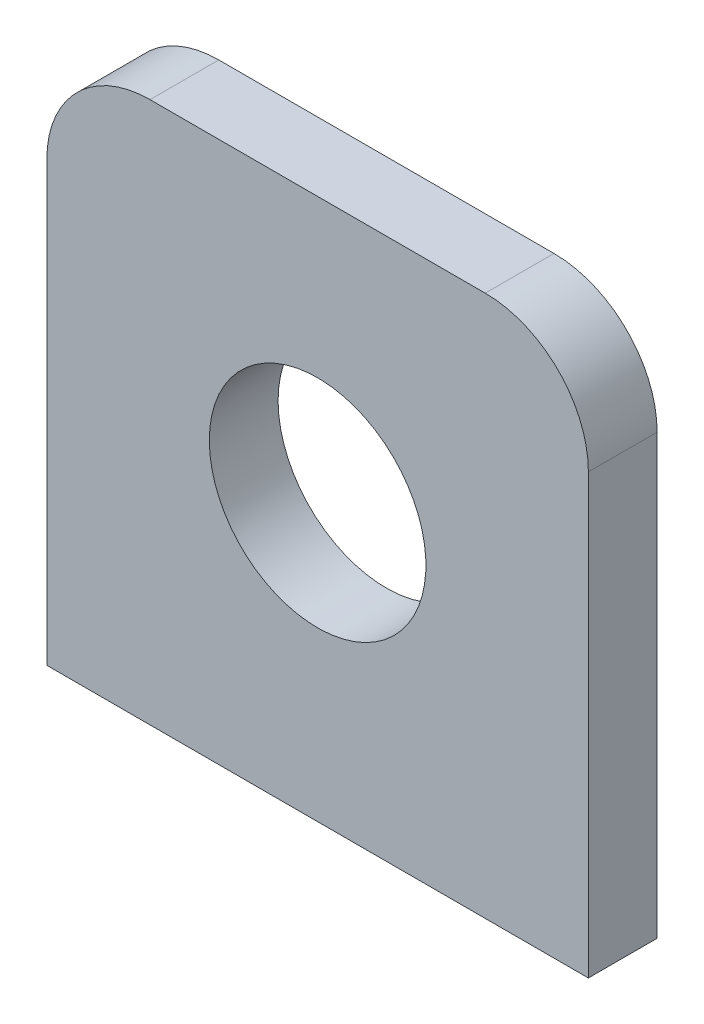
from build123d import *

# Parameters (mm, degrees)
ESBO_O1_W                        = 50
ESBO_O1_H                        = 50
RESSALTO_EXTRUS_O1_DEPTH         = 6.35
FURO_COM_FOLGA_DE_M131_D         = 20
FURO_DE_DI_METRO_3_3_3_3_2_D     = 3.3
FURO_DE_DI_METRO_3_3_3_3_2_DEPTH = 9.1
FURO_DE_DI_METRO_3_3_3_3_2_TIP   = 0.991420021
FILETE1_R                        = 9.525


with BuildPart() as part:
    # Esboço1 → Ressalto-extrusão1 (new body)
    with BuildSketch(Plane.XY.offset(6.35)):
        with Locations((12, 25)):
            Rectangle(ESBO_O1_W, ESBO_O1_H)
    extrude(amount=-RESSALTO_EXTRUS_O1_DEPTH)

    # Furo com folga de M131 (through all)
    with Locations(Plane(origin=(0, 0, 0), x_dir=(-1, 0, 0), z_dir=(0, 0, -1))):
        with Locations((-12, 25.5)):
            Hole(FURO_COM_FOLGA_DE_M131_D / 2)

    # Furo de diâmetro Ø3.3 (3.3)2
    with Locations(Plane(origin=(0, 0, 0), x_dir=(-1, 0, 0), z_dir=(0, -1, 0))):
        with Locations((5.5, -3.175), (-29.5, -3.175)):
            Hole(FURO_DE_DI_METRO_3_3_3_3_2_D / 2, depth=FURO_DE_DI_METRO_3_3_3_3_2_DEPTH)
            with Locations((0, 0, -(FURO_DE_DI_METRO_3_3_3_3_2_DEPTH + FURO_DE_DI_METRO_3_3_3_3_2_TIP / 2))):  # 118° drill point
                Cone(0, FURO_DE_DI_METRO_3_3_3_3_2_D / 2, FURO_DE_DI_METRO_3_3_3_3_2_TIP, mode=Mode.SUBTRACT)

    # Filete1
    filete1_edges = [part.edges().sort_by_distance(p)[0] for p in [
        (-13, 50, 3.175),
        (37, 50, 3.175),
    ]]
    fillet(filete1_edges, radius=FILETE1_R)


solid = part.part
